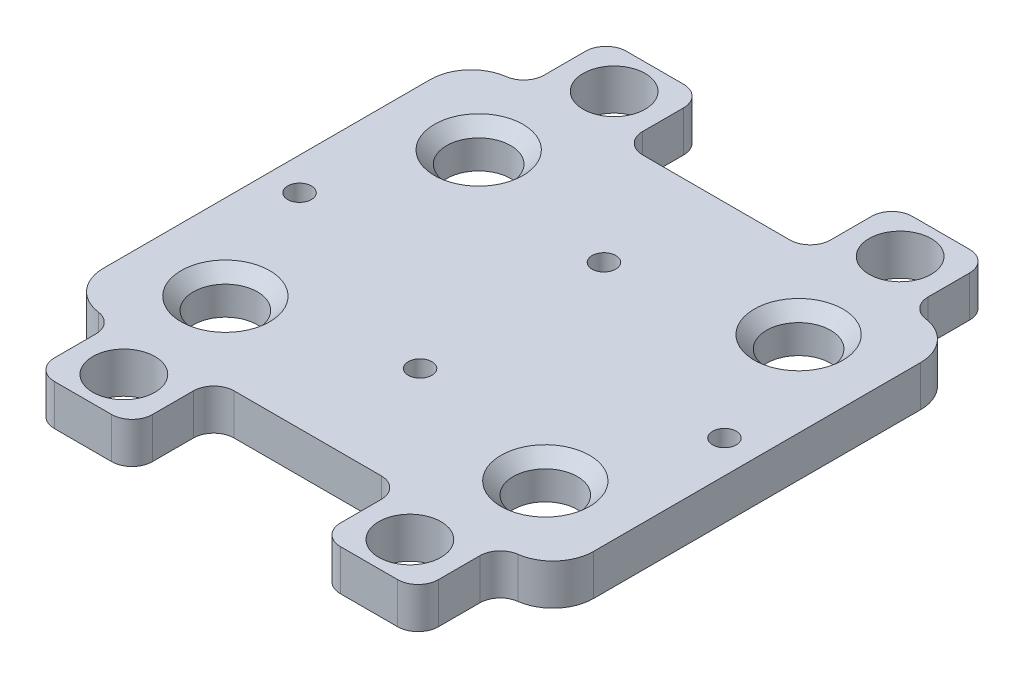
from build123d import *

# Parameters (mm, degrees)
SKETCH1_W           = 50
SKETCH1_H           = 5
BOSS_EXTRUDE1_DEPTH = 60
SKETCH2_R           = 3.925
SKETCH2_R_2         = 1.45
CUT_EXTRUDE1_DEPTH  = 79.262379212
CHAMFER1_SIZE       = 1.5
FILLET2_R           = 5
SKETCH2_3_W         = 12
SKETCH2_3_H         = 10
SKETCH2_3_R         = 3.8
BOSS_EXTRUDE2_DEPTH = 5
FILLET5_R           = 2.5
FILLET6_R           = 2.5
CHAMFER2_SIZE       = 1.5
CHAMFER3_SIZE       = 1.5


with BuildPart() as part:
    # Sketch1 → Boss-Extrude1 (new body)
    with BuildSketch(Plane(origin=(0, 0, 0), x_dir=(0, 0, -1), z_dir=(1, 0, 0))):
        with Locations((25, 2.5)):
            Rectangle(SKETCH1_W, SKETCH1_H)
    extrude(amount=BOSS_EXTRUDE1_DEPTH)

    # Sketch2 → Cut-Extrude1 (cut, through all)
    with BuildSketch(Plane(origin=(0, 5, 0), x_dir=(1, 0, 0), z_dir=(0, 1, 0))):
        with Locations((49.575, 40.5)):
            Circle(SKETCH2_R)
        with Locations((10.425, 40.5)):
            Circle(SKETCH2_R)
        with Locations((10.425, 9.5)):
            Circle(SKETCH2_R)
        with Locations((49.575, 9.5)):
            Circle(SKETCH2_R)
        with Locations((30, 36.25)):
            Circle(SKETCH2_R_2)
        with Locations((30, 13.75)):
            Circle(SKETCH2_R_2)
        with Locations((56, 25)):
            Circle(SKETCH2_R_2)
        with Locations((4, 25)):
            Circle(SKETCH2_R_2)
    extrude(amount=-CUT_EXTRUDE1_DEPTH, mode=Mode.SUBTRACT)

    # Chamfer1
    chamfer1_edges = [part.edges().sort_by_distance(p)[0] for p in [
        (6.5, 5, -9.5),
        (45.65, 5, -9.5),
        (6.5, 5, -40.5),
        (45.65, 5, -40.5),
    ]]
    chamfer(chamfer1_edges, length=CHAMFER1_SIZE)

    # Fillet2
    fillet2_edges = [part.edges().sort_by_distance(p)[0] for p in [
        (0, 2.5, -50),
        (0, 2.5, 0),
        (60, 2.5, 0),
        (60, 2.5, -50),
    ]]
    fillet(fillet2_edges, radius=FILLET2_R)

    # Sketch2_3 → Boss-Extrude2 (add)
    # profile 1 of 4: a face of its own
    with BuildSketch(Plane(origin=(0, 5, 0), x_dir=(1, 0, 0), z_dir=(0, 1, 0))):
        with Locations((47.5, 55)):
            Rectangle(SKETCH2_3_W, SKETCH2_3_H)
        with Locations((47.5, 55)):
            Circle(SKETCH2_3_R, mode=Mode.SUBTRACT)
    # profile 2 of 4: a face of its own
    with BuildSketch(Plane(origin=(0, 5, 0), x_dir=(1, 0, 0), z_dir=(0, 1, 0))):
        with Locations((12.5, 55)):
            Rectangle(SKETCH2_3_W, SKETCH2_3_H)
        with Locations((12.5, 55)):
            Circle(SKETCH2_3_R, mode=Mode.SUBTRACT)
    # profile 3 of 4: a face of its own
    with BuildSketch(Plane(origin=(0, 5, 0), x_dir=(1, 0, 0), z_dir=(0, 1, 0))):
        with Locations((47.5, -5)):
            Rectangle(SKETCH2_3_W, SKETCH2_3_H)
        with Locations((47.5, -5)):
            Circle(SKETCH2_3_R, mode=Mode.SUBTRACT)
    # profile 4 of 4: a face of its own
    with BuildSketch(Plane(origin=(0, 5, 0), x_dir=(1, 0, 0), z_dir=(0, 1, 0))):
        with Locations((12.5, -5)):
            Rectangle(SKETCH2_3_W, SKETCH2_3_H)
        with Locations((12.5, -5)):
            Circle(SKETCH2_3_R, mode=Mode.SUBTRACT)
    extrude(amount=-BOSS_EXTRUDE2_DEPTH)

    # Fillet5
    fillet5_edges = [part.edges().sort_by_distance(p)[0] for p in [
        (41.5, 2.5, 10),
        (53.5, 2.5, 10),
        (6.5, 2.5, 10),
        (18.5, 2.5, 10),
        (53.5, 2.5, -60),
        (41.5, 2.5, -60),
        (6.5, 2.5, -60),
        (18.5, 2.5, -60),
    ]]
    fillet(fillet5_edges, radius=FILLET5_R)

    # Fillet6
    fillet6_edges = [part.edges().sort_by_distance(p)[0] for p in [
        (18.5, 2.5, 0),
        (53.5, 2.5, 0),
        (6.5, 2.5, 0),
        (41.5, 2.5, 0),
        (6.5, 2.5, -50),
        (41.5, 2.5, -50),
        (53.5, 2.5, -50),
        (18.5, 2.5, -50),
    ]]
    fillet(fillet6_edges, radius=FILLET6_R)

    # Chamfer2
    chamfer2_edges = [part.edges().sort_by_distance(p)[0] for p in [
        (28.55, 0, -13.75),
        (54.55, 0, -25),
        (28.55, 0, -36.25),
    ]]
    chamfer(chamfer2_edges, length=CHAMFER2_SIZE)

    # Chamfer3
    chamfer3_edges = [part.edges().sort_by_distance(p)[0] for p in [
        (2.55, 0, -25),
    ]]
    chamfer(chamfer3_edges, length=CHAMFER3_SIZE)


solid = part.part
